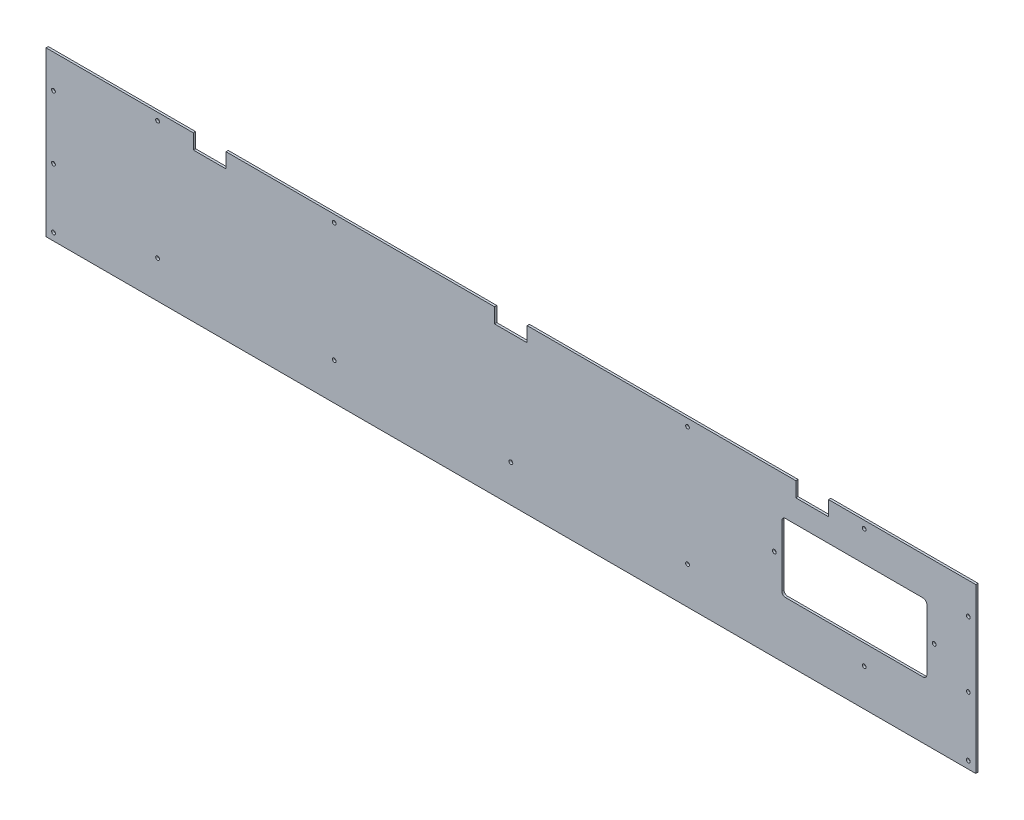
from build123d import *

# Parameters (mm, degrees)
SKETCH1_R           = 2.55
BOSS_EXTRUDE1_DEPTH = 3


with BuildPart() as part:
    # Sketch1 → Boss-Extrude1 (new body)
    with BuildSketch(Plane.XY):
        Polygon((431.898025048, 87.861768757), (629.898025048, 87.861768757), (629.898025048, -132.138231243), (-620.101974952, -132.138231243), (-620.101974952, 87.861768757), (-422.101974952, 87.861768757), (-422.101974952, 67.861768757), (-378.101974952, 67.861768757), (-378.101974952, 87.861768757), (-17.101974952, 87.861768757), (-17.101974952, 67.861768757), (26.898025048, 67.861768757), (26.898025048, 87.861768757), (387.898025048, 87.861768757), (387.898025048, 67.861768757), (431.898025048, 67.861768757), align=None)
        with Locations((242.398025048, 77.861768757)):
            Circle(SKETCH1_R, mode=Mode.SUBTRACT)
        with Locations((-610.101974952, 42.861768757)):
            Circle(SKETCH1_R, mode=Mode.SUBTRACT)
        with Locations((-232.601974952, 77.861768757)):
            Circle(SKETCH1_R, mode=Mode.SUBTRACT)
        with Locations((-470.101974952, 77.861768757)):
            Circle(SKETCH1_R, mode=Mode.SUBTRACT)
        with Locations((479.898025048, 77.861768757)):
            Circle(SKETCH1_R, mode=Mode.SUBTRACT)
        with Locations((479.898025048, -82.138231243)):
            Circle(SKETCH1_R, mode=Mode.SUBTRACT)
        with Locations((242.398025048, -82.138231243)):
            Circle(SKETCH1_R, mode=Mode.SUBTRACT)
        with Locations((4.898025048, -82.138231243)):
            Circle(SKETCH1_R, mode=Mode.SUBTRACT)
        with Locations((-232.601974952, -82.138231243)):
            Circle(SKETCH1_R, mode=Mode.SUBTRACT)
        with Locations((-470.101974952, -82.138231243)):
            Circle(SKETCH1_R, mode=Mode.SUBTRACT)
        with Locations((619.898025048, -42.138231243)):
            Circle(SKETCH1_R, mode=Mode.SUBTRACT)
        with Locations((-610.101974952, -42.138231243)):
            Circle(SKETCH1_R, mode=Mode.SUBTRACT)
        with Locations((-610, -122.138231243)):
            Circle(SKETCH1_R, mode=Mode.SUBTRACT)
        with Locations((619.898025048, 45.705315607)):
            Circle(SKETCH1_R, mode=Mode.SUBTRACT)
        with Locations((619.898025048, -122.138231243)):
            Circle(SKETCH1_R, mode=Mode.SUBTRACT)
        with Locations((574.10958906, -9.140897424)):
            Circle(SKETCH1_R, mode=Mode.SUBTRACT)
        with Locations((359.10958906, -9.140897424)):
            Circle(SKETCH1_R, mode=Mode.SUBTRACT)
        with BuildLine():
            Line((559.10958906, 36.859102576), (374.10958906, 36.859102576))
            ThreePointArc((374.10958906, 36.859102576), (370.574055154, 35.394636482), (369.10958906, 31.859102576))
            Line((369.10958906, 31.859102576), (369.10958906, -50.140897424))
            ThreePointArc((369.10958906, -50.140897424), (370.574055154, -53.67643133), (374.10958906, -55.140897424))
            Line((374.10958906, -55.140897424), (559.10958906, -55.140897424))
            ThreePointArc((559.10958906, -55.140897424), (562.645122966, -53.67643133), (564.10958906, -50.140897424))
            Line((564.10958906, -50.140897424), (564.10958906, 31.859102576))
            ThreePointArc((564.10958906, 31.859102576), (562.645122966, 35.394636482), (559.10958906, 36.859102576))
        make_face(mode=Mode.SUBTRACT)
    extrude(amount=BOSS_EXTRUDE1_DEPTH)


solid = part.part
